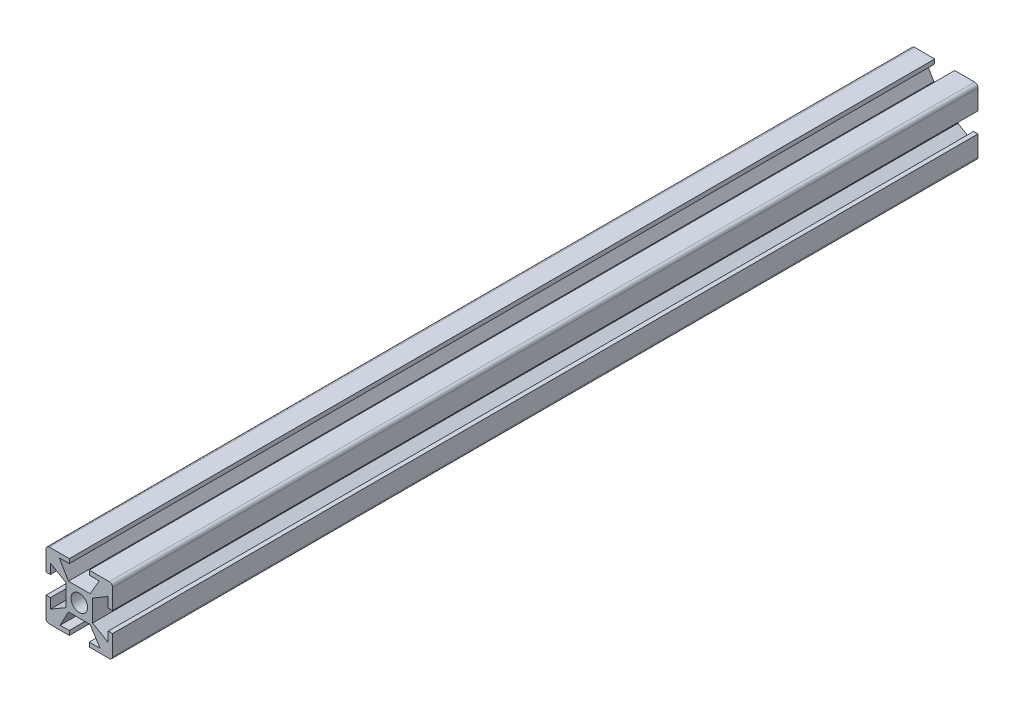
from build123d import *

# Parameters (mm, degrees)
CROQUIS1_W              = 8
CROQUIS1_H              = 8
CROQUIS1_R              = 2.5
SALIENTE_EXTRUIR4_DEPTH = 260


with BuildPart() as part:
    # Croquis1 → Saliente-Extruir4 (new body)
    with BuildSketch(Plane.XY):
        with BuildLine():
            Line((-3, 8.7), (-3, 10))
            Line((-3, 10), (-9, 10))
            ThreePointArc((-9, 10), (-9.707106781, 9.707106781), (-10, 9))
            Line((-10, 9), (-10, 3))
            Line((-10, 3), (-8.7, 3))
            Line((-8.7, 3), (-8.7, 6))
            Line((-8.7, 6), (-4, 3.25))
            Line((-4, 3.25), (-4, 4))
            Line((-4, 4), (-3.25, 4))
            Line((-3.25, 4), (-6, 8.7))
            Line((-6, 8.7), (-3, 8.7))
        make_face()
        with BuildLine():
            Line((9, 10), (3, 10))
            Line((3, 10), (3, 8.7))
            Line((3, 8.7), (6, 8.7))
            Line((6, 8.7), (3.25, 4))
            Line((3.25, 4), (4, 4))
            Line((4, 4), (4, 3.25))
            Line((4, 3.25), (8.7, 6))
            Line((8.7, 6), (8.7, 3))
            Line((8.7, 3), (10, 3))
            Line((10, 3), (10, 9))
            ThreePointArc((10, 9), (9.707106781, 9.707106781), (9, 10))
        make_face()
        with BuildLine():
            Line((10, -9), (10, -3))
            Line((10, -3), (8.7, -3))
            Line((8.7, -3), (8.7, -6))
            Line((8.7, -6), (4, -3.25))
            Line((4, -3.25), (4, -4))
            Line((4, -4), (3.25, -4))
            Line((3.25, -4), (6.25, -8.7))
            Line((6.25, -8.7), (3, -8.7))
            Line((3, -8.7), (3, -10))
            Line((3, -10), (9, -10))
            ThreePointArc((9, -10), (9.707106781, -9.707106781), (10, -9))
        make_face()
        with BuildLine():
            Line((-8.7, -3), (-10, -3))
            Line((-10, -3), (-10, -9))
            ThreePointArc((-10, -9), (-9.707106781, -9.707106781), (-9, -10))
            Line((-9, -10), (-3, -10))
            Line((-3, -10), (-3, -8.7))
            Line((-3, -8.7), (-5.75, -8.7))
            Line((-5.75, -8.7), (-3.25, -4))
            Line((-3.25, -4), (-4, -4))
            Line((-4, -4), (-4, -3.25))
            Line((-4, -3.25), (-8.7, -6))
            Line((-8.7, -6), (-8.7, -3))
        make_face()
        Rectangle(CROQUIS1_W, CROQUIS1_H)
        Circle(CROQUIS1_R, mode=Mode.SUBTRACT)
    extrude(amount=SALIENTE_EXTRUIR4_DEPTH)


solid = part.part
